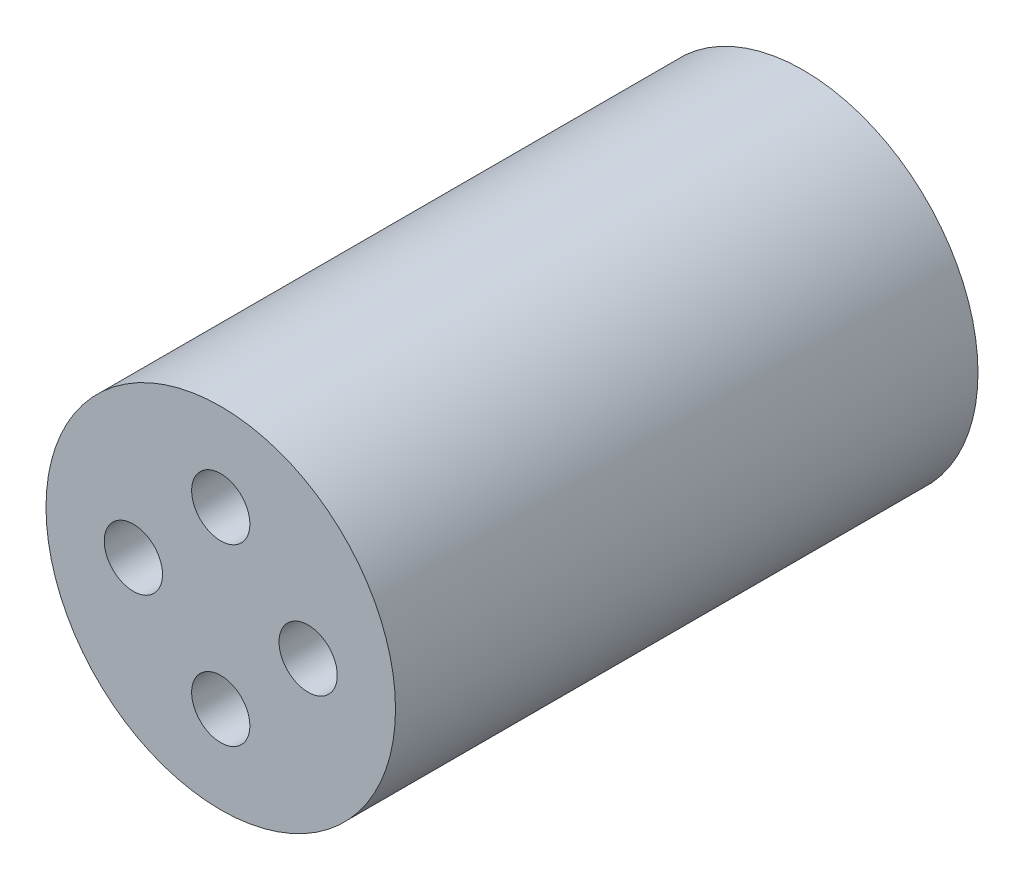
from build123d import *

# Parameters (mm, degrees)
SKETCH_1_R      = 6
SKETCH_1_R_2    = 1
EXTRUDE_1_DEPTH = 20


with BuildPart() as part:
    # ｽｹｯﾁ1 → ﾎﾞｽ - 押し出し1 (new body)
    with BuildSketch(Plane.XY):
        Circle(SKETCH_1_R)
        with Locations((0, 3)):
            Circle(SKETCH_1_R_2, mode=Mode.SUBTRACT)
        with Locations((3, 0)):
            Circle(SKETCH_1_R_2, mode=Mode.SUBTRACT)
        with Locations((0, -3)):
            Circle(SKETCH_1_R_2, mode=Mode.SUBTRACT)
        with Locations((-3, 0)):
            Circle(SKETCH_1_R_2, mode=Mode.SUBTRACT)
    extrude(amount=EXTRUDE_1_DEPTH)


solid = part.part
